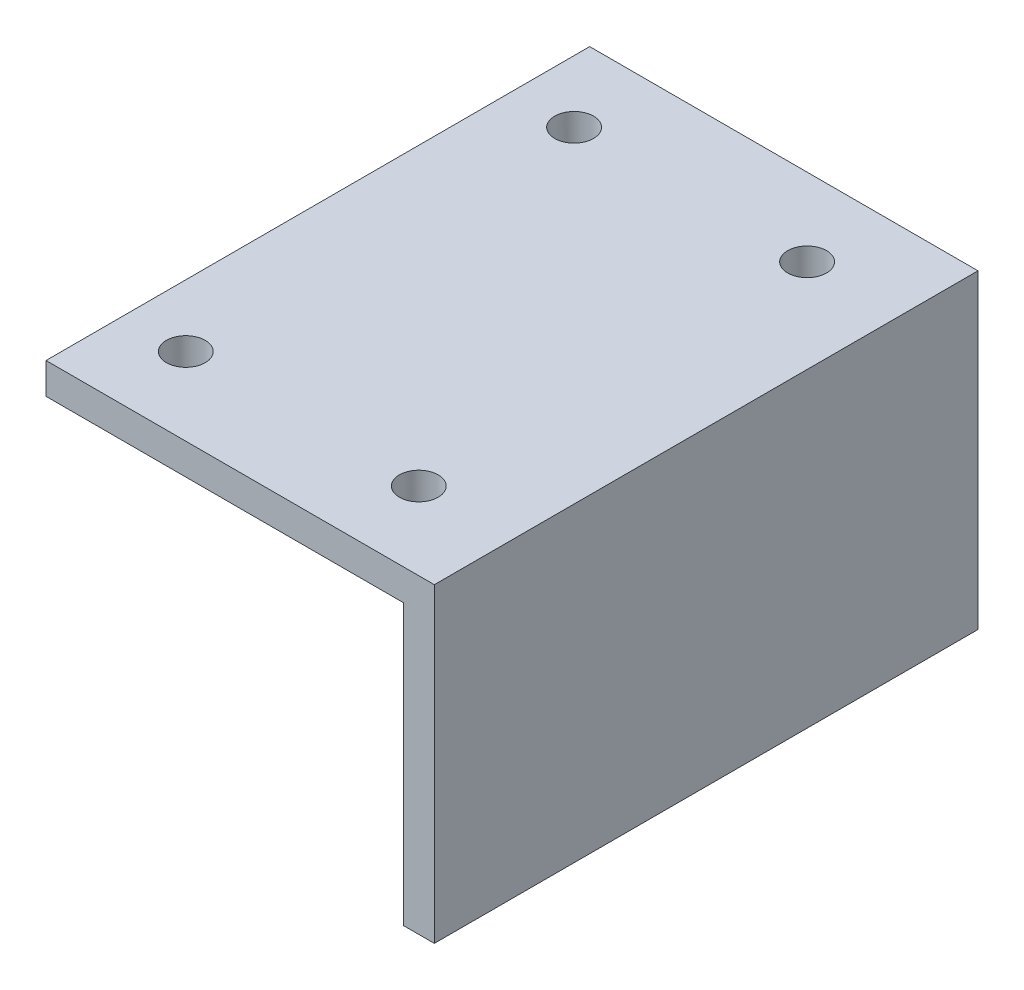
from build123d import *

# Parameters (mm, degrees)
SALIENTE_EXTRUIR1_DEPTH      = 35
SALIENTE_EXTRUIR1_DEPTH_BACK = 35
CROQUIS3_R                   = 2.5
CORTAR_EXTRUIR1_DEPTH        = 4
CROQUIS4_W                   = 70
CROQUIS4_H                   = 10
CORTAR_EXTRUIR2_DEPTH        = 10


with BuildPart() as part:
    # Croquis2 → Saliente-Extruir1 (new body, two sides)
    with BuildSketch(Plane.XY) as saliente_extruir1_sk:
        Polygon((0, 0), (-50, 0), (-50, -4), (-4, -4), (-4, -50), (0, -50), align=None)
    extrude(amount=SALIENTE_EXTRUIR1_DEPTH)
    extrude(saliente_extruir1_sk.sketch, amount=-SALIENTE_EXTRUIR1_DEPTH_BACK)

    # Croquis3 → Cortar-Extruir1 (cut)
    with BuildSketch(Plane.XZ.offset(4)):
        with Locations((-12, 25)):
            Circle(CROQUIS3_R)
        with Locations((-12, -25)):
            Circle(CROQUIS3_R)
        with Locations((-42, 25)):
            Circle(CROQUIS3_R)
        with Locations((-42, -25)):
            Circle(CROQUIS3_R)
    extrude(amount=-CORTAR_EXTRUIR1_DEPTH, mode=Mode.SUBTRACT)

    # Croquis4 → Cortar-Extruir2 (cut)
    with BuildSketch(Plane.ZY.offset(4)):
        with Locations((0, -45)):
            Rectangle(CROQUIS4_W, CROQUIS4_H)
    extrude(amount=-CORTAR_EXTRUIR2_DEPTH, mode=Mode.SUBTRACT)


solid = part.part
